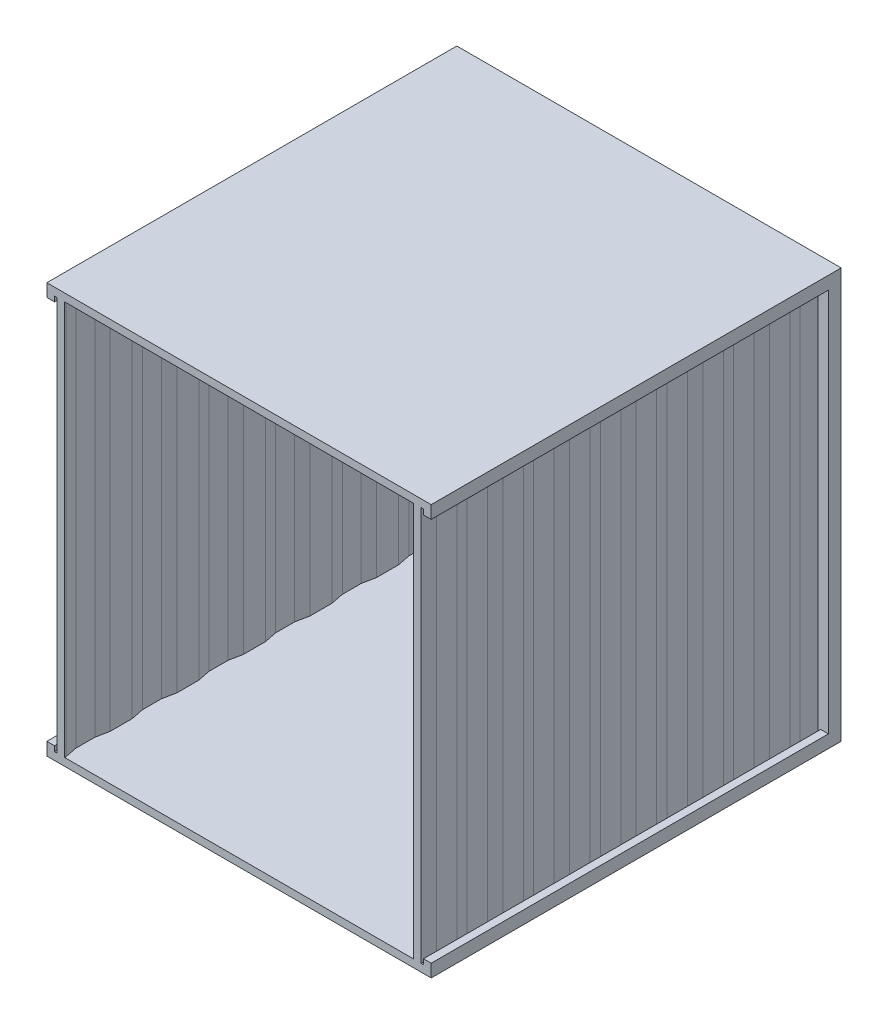
from build123d import *

# Parameters (mm, degrees)
SKETCH1_W           = 150
SKETCH1_H           = 160
SKETCH1_W_2         = 130
SKETCH1_H_2         = 140
BOSS_EXTRUDE1_DEPTH = 5
BOSS_EXTRUDE2_DEPTH = 155
BOSS_EXTRUDE3_DEPTH = 154
SKETCH4_W           = 155
SKETCH4_H           = 3
BOSS_EXTRUDE4_DEPTH = 140
SKETCH5_W           = 155
SKETCH5_H           = 3
BOSS_EXTRUDE5_DEPTH = 140


with BuildPart() as part:
    # Sketch1 → Boss-Extrude1 (new body)
    with BuildSketch(Plane.XY):
        Rectangle(SKETCH1_W, SKETCH1_H)
        Rectangle(SKETCH1_W_2, SKETCH1_H_2, mode=Mode.SUBTRACT)
    extrude(amount=BOSS_EXTRUDE1_DEPTH)

    # Sketch2 → Boss-Extrude2 (add)
    with BuildSketch(Plane.XY.offset(5)):
        Polygon((-75, 80), (-70, 80), (-70, 77), (-72, 77), (-72, 75), (-75, 75), align=None)
        Polygon((72, 75), (75, 75), (75, 80), (70, 80), (70, 77), (72, 77), align=None)
        Polygon((75, -75), (75, -80), (70, -80), (70, -77), (72, -77), (72, -75), align=None)
        Polygon((-70, -80), (-70, -77), (-72, -77), (-72, -75), (-75, -75), (-75, -80), align=None)
    extrude(amount=BOSS_EXTRUDE2_DEPTH)

    # Sketch3 → Boss-Extrude3 (add)
    with BuildSketch(Plane(origin=(0, -77, 0), x_dir=(1, 0, 0), z_dir=(0, 1, 0))):
        Polygon((-71, -160), (-72, -155), (-72, -147), (-71, -142), (-71, -134), (-72, -129), (-72, -121), (-71, -116), (-71, -108), (-72, -103), (-72, -95), (-71, -90), (-71, -82), (-72, -77), (-72, -69), (-71, -64), (-71, -56), (-72, -51), (-72, -43), (-71, -38), (-71, -30), (-72, -25), (-72, -17), (-71, -12), (-71, -5), (-68, -5), (-68, -12.297058541), (-69, -17.297058541), (-69, -24.702941459), (-68, -29.702941459), (-68, -38.297058541), (-69, -43.297058541), (-69, -50.702941459), (-68, -55.702941459), (-68, -64.297058541), (-69, -69.297058541), (-69, -76.702941459), (-68, -81.702941459), (-68, -90.297058541), (-69, -95.297058541), (-69, -102.702941459), (-68, -107.702941459), (-68, -116.297058541), (-69, -121.297058541), (-69, -128.702941459), (-68, -133.702941459), (-68, -142.297058541), (-69, -147.297058541), (-69, -154.702941459), (-68.058257973, -159.411651595), (-68.058257973, -160), align=None)
    boss_extrude3 = extrude(amount=BOSS_EXTRUDE3_DEPTH)

    # Mirror1: Boss-Extrude3 across plane
    add(boss_extrude3.mirror(Plane(origin=(0, 0, 0), x_dir=(0, 0, 1), z_dir=(1, 0, 0))))

    # Sketch4 → Boss-Extrude4 (add)
    with BuildSketch(Plane(origin=(-70, 0, 0), x_dir=(0, 0, -1), z_dir=(1, 0, 0))):
        with Locations((-82.5, 78.5)):
            Rectangle(SKETCH4_W, SKETCH4_H)
    extrude(amount=BOSS_EXTRUDE4_DEPTH)

    # Sketch5 → Boss-Extrude5 (add)
    with BuildSketch(Plane(origin=(-70, 0, 0), x_dir=(0, 0, -1), z_dir=(1, 0, 0))):
        with Locations((-82.5, -78.5)):
            Rectangle(SKETCH5_W, SKETCH5_H)
    extrude(amount=BOSS_EXTRUDE5_DEPTH)


solid = part.part
